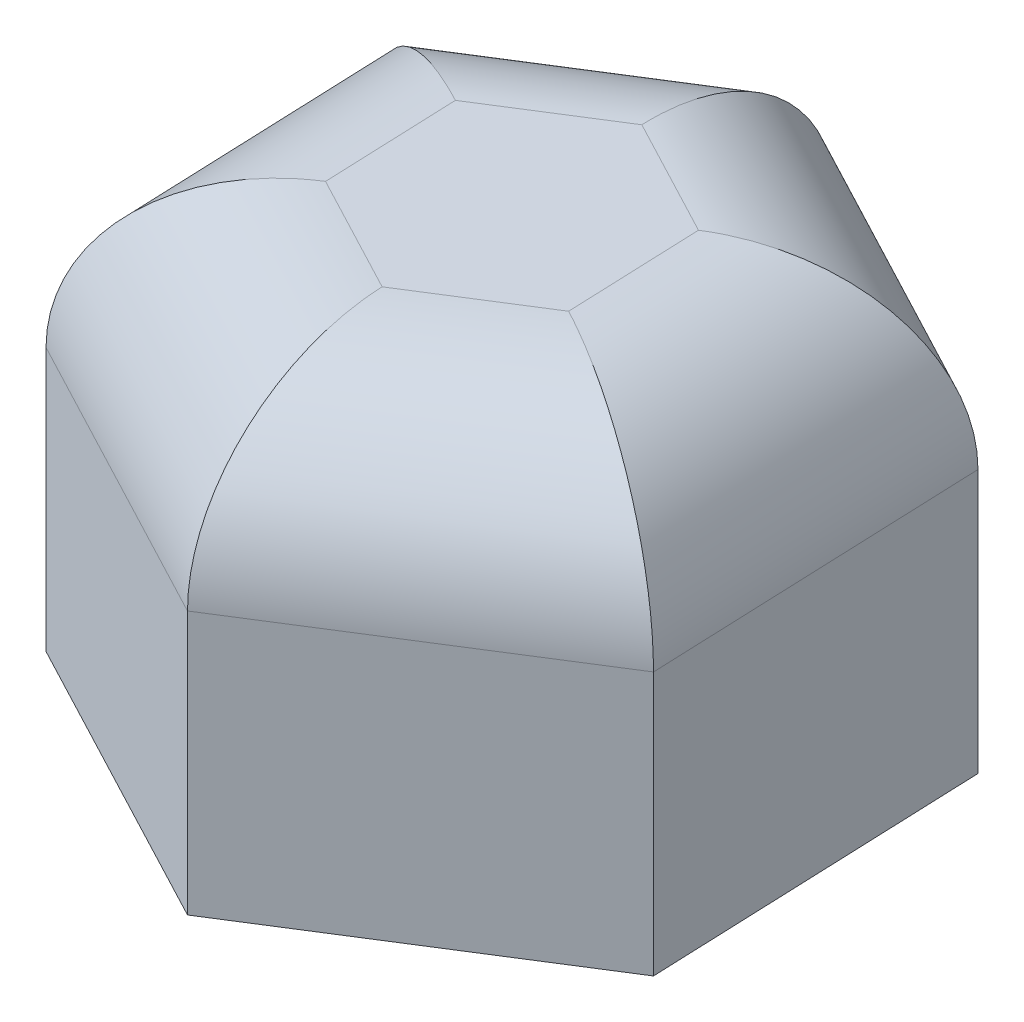
from build123d import *

# Parameters (mm, degrees)
BOSS_EXTRUDE1_DEPTH = 10
FILLET1_R           = 4
SKETCH2_R           = 4.1
CUT_EXTRUDE1_DEPTH  = 8


with BuildPart() as part:
    # Sketch1 → Boss-Extrude1 (new body)
    with BuildSketch(Plane(origin=(0, 0, 0), x_dir=(1, 0, 0), z_dir=(0, 1, 0))):
        Polygon((-6.812793916, 3.588291941), (-6.513948935, -4.105906632), (0.298844981, -7.694198573), (6.812793916, -3.588291941), (6.513948935, 4.105906632), (-0.298844981, 7.694198573), align=None)
    extrude(amount=BOSS_EXTRUDE1_DEPTH)

    # Fillet1
    fillet1_edges = [part.edges().sort_by_distance(p)[0] for p in [
        (-3.107551977, 10, 5.900052602),
        (3.555819448, 10, 5.641245257),
        (6.663371426, 10, -0.258807345),
        (3.107551977, 10, -5.900052602),
        (-3.555819448, 10, -5.641245257),
        (-6.663371426, 10, 0.258807345),
    ]]
    fillet(fillet1_edges, radius=FILLET1_R)

    # Sketch2 → Cut-Extrude1 (cut)
    with BuildSketch(Plane.XZ):
        Circle(SKETCH2_R)
    extrude(amount=-CUT_EXTRUDE1_DEPTH, mode=Mode.SUBTRACT)


solid = part.part
